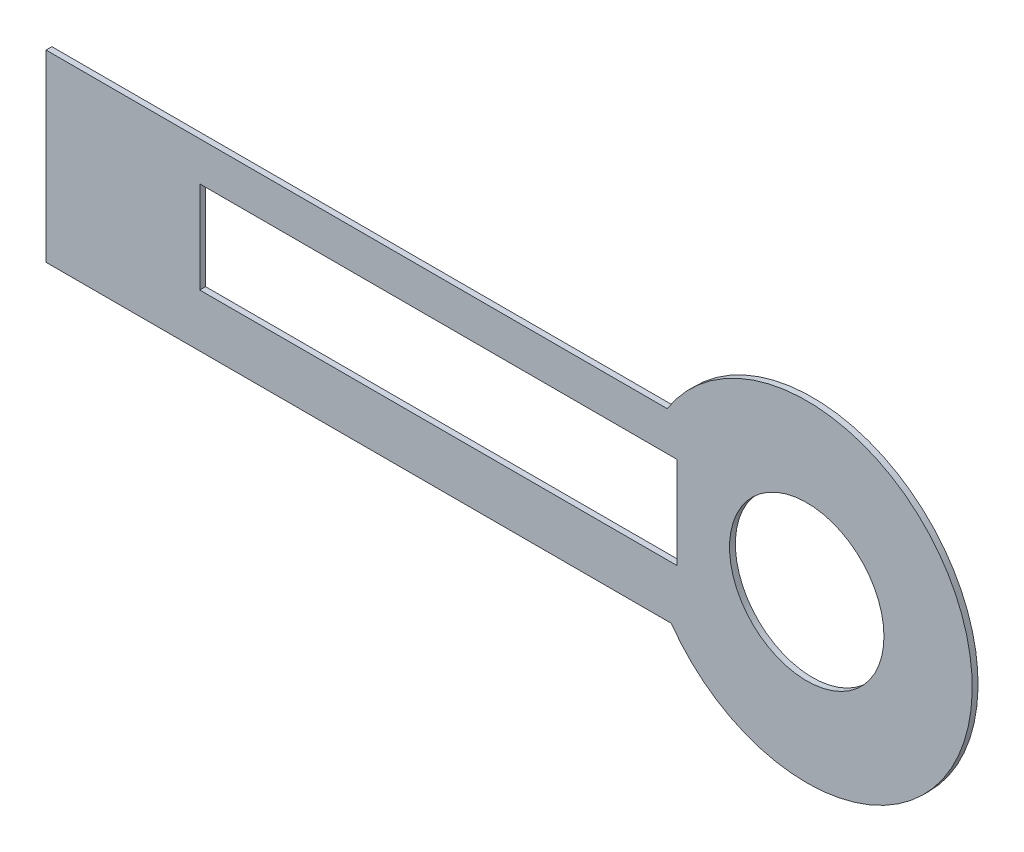
from build123d import *

# Parameters (mm, degrees)
BOSS_EXTRUDE2_DEPTH = 0.3175
SKETCH3_R           = 4.2
SKETCH3_W           = 25.956624075
SKETCH3_H           = 5
CUT_EXTRUDE1_DEPTH  = 1.3175


with BuildPart() as part:
    # Sketch2 → Boss-Extrude2 (new body)
    with BuildSketch(Plane.XY):
        with BuildLine():
            Line((-6.375715531, -5.168393782), (-6.375715531, 4.831606218))
            Line((-6.375715531, 4.831606218), (-7.593127245, 4.831606218))
            ThreePointArc((-7.593127245, 4.831606218), (-8.997720551, -0.202546003), (-7.368019117, -5.168393782))
            Line((-7.368019117, -5.168393782), (-6.375715531, -5.168393782))
        make_face()
        with BuildLine():
            Line((-7.593127245, 4.831606218), (-6.375715531, 4.831606218))
            Line((-6.375715531, 4.831606218), (-6.375715531, -5.168393782))
            Line((-6.375715531, -5.168393782), (-7.368019117, -5.168393782))
            ThreePointArc((-7.368019117, -5.168393782), (2.709965677, -8.582312394), (9, 0))
            ThreePointArc((9, 0), (2.516133422, 8.641126813), (-7.593127245, 4.831606218))
        make_face()
        with BuildLine():
            ThreePointArc((-7.368019117, -5.168393782), (-8.997720551, -0.202546003), (-7.593127245, 4.831606218))
            Line((-7.593127245, 4.831606218), (-41.375715531, 4.831606218))
            Line((-41.375715531, 4.831606218), (-41.375715531, -5.168393782))
            Line((-41.375715531, -5.168393782), (-7.368019117, -5.168393782))
        make_face()
    extrude(amount=BOSS_EXTRUDE2_DEPTH)

    # Sketch3 → Cut-Extrude1 (cut, through all)
    with BuildSketch(Plane.XY.offset(0.3175)):
        Circle(SKETCH3_R)
        with Locations((-20.034010662, 0.207958654)):
            Rectangle(SKETCH3_W, SKETCH3_H)
    extrude(amount=-CUT_EXTRUDE1_DEPTH, mode=Mode.SUBTRACT)


solid = part.part
